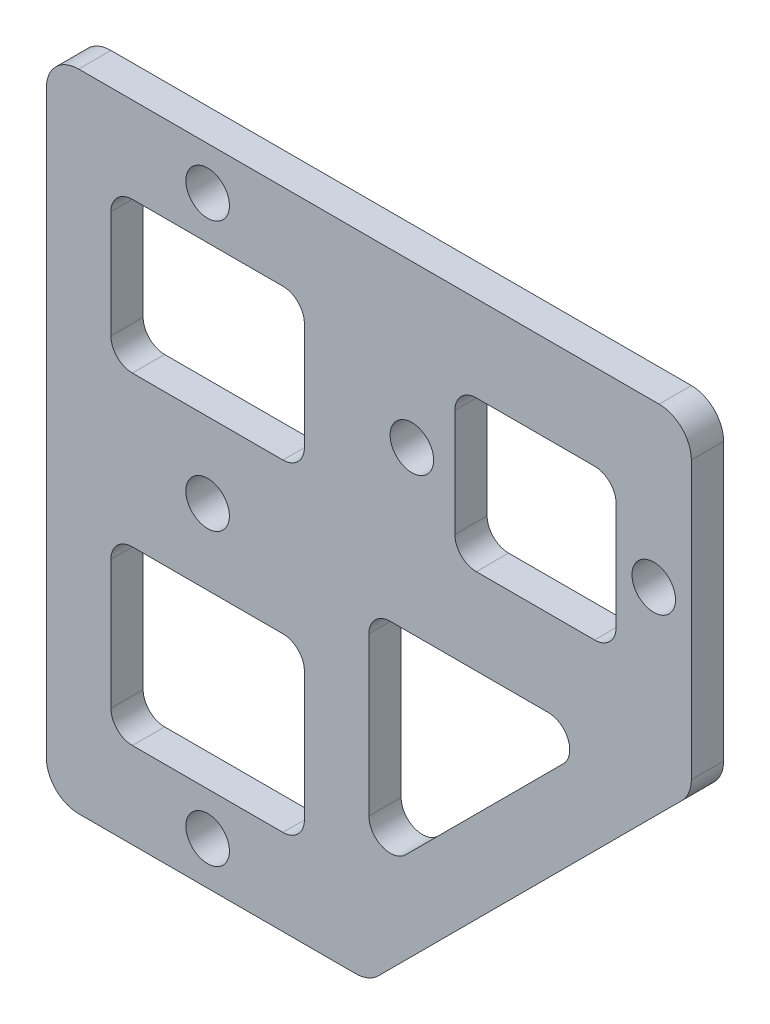
from build123d import *

# Parameters (mm, degrees)
EXTRUDE_1_DEPTH     = 3
SKETCH_2_W          = 18
SKETCH_2_H          = 14
SKETCH_2_H_2        = 16
SKETCH_2_W_2        = 15
CUT_EXTRUDE_1_DEPTH = 10
FILLET_1_R          = 2
FILLET_2_R          = 3
SKETCH_4_R          = 2.025
CUT_EXTRUDE_2_DEPTH = 10
SKETCH_5_R          = 2.025
CUT_EXTRUDE_3_DEPTH = 10


with BuildPart() as part:
    # 草图1 → 凸台-拉伸1 (new body)
    with BuildSketch(Plane.XY):
        Polygon((0, 0), (60, 0), (60, -30), (30, -60), (0, -60), align=None)
    extrude(amount=EXTRUDE_1_DEPTH)

    # 草图2 → 切除-拉伸1 (cut)
    with BuildSketch(Plane.XY.offset(3)):
        Polygon((30, -51.514718626), (30, -30), (51.514718626, -30), align=None)
        with Locations((15, -15)):
            Rectangle(SKETCH_2_W, SKETCH_2_H)
        with Locations((15, -44)):
            Rectangle(SKETCH_2_W, SKETCH_2_H_2)
        with Locations((45.5, -15)):
            Rectangle(SKETCH_2_W_2, SKETCH_2_H)
    extrude(amount=-CUT_EXTRUDE_1_DEPTH, mode=Mode.SUBTRACT)

    # 圆角1
    fillet_1_edges = [part.edges().sort_by_distance(p)[0] for p in [
        (53, -8, 1.5),
        (53, -22, 1.5),
        (38, -22, 1.5),
        (38, -8, 1.5),
        (51.514718626, -30, 1.5),
        (30, -51.514718626, 1.5),
        (30, -30, 1.5),
        (24, -36, 1.5),
        (24, -52, 1.5),
        (6, -52, 1.5),
        (6, -36, 1.5),
        (24, -8, 1.5),
        (24, -22, 1.5),
        (6, -22, 1.5),
        (6, -8, 1.5),
    ]]
    fillet(fillet_1_edges, radius=FILLET_1_R)

    # 圆角2
    fillet_2_edges = [part.edges().sort_by_distance(p)[0] for p in [
        (0, 0, 1.5),
        (60, 0, 1.5),
        (60, -30, 1.5),
        (30, -60, 1.5),
        (0, -60, 1.5),
    ]]
    fillet(fillet_2_edges, radius=FILLET_2_R)

    # 草图4 → 切除-拉伸2 (cut)
    with BuildSketch(Plane.XY.offset(3)):
        with Locations((15, -29)):
            Circle(SKETCH_4_R)
        with Locations((15, -56)):
            Circle(SKETCH_4_R)
        with Locations((15, -4)):
            Circle(SKETCH_4_R)
    extrude(amount=-CUT_EXTRUDE_2_DEPTH, mode=Mode.SUBTRACT)

    # 草图5 → 切除-拉伸3 (cut)
    with BuildSketch(Plane.XY.offset(3)):
        with Locations((34, -15)):
            Circle(SKETCH_5_R)
        with Locations((56.5, -15)):
            Circle(SKETCH_5_R)
    extrude(amount=-CUT_EXTRUDE_3_DEPTH, mode=Mode.SUBTRACT)


solid = part.part
